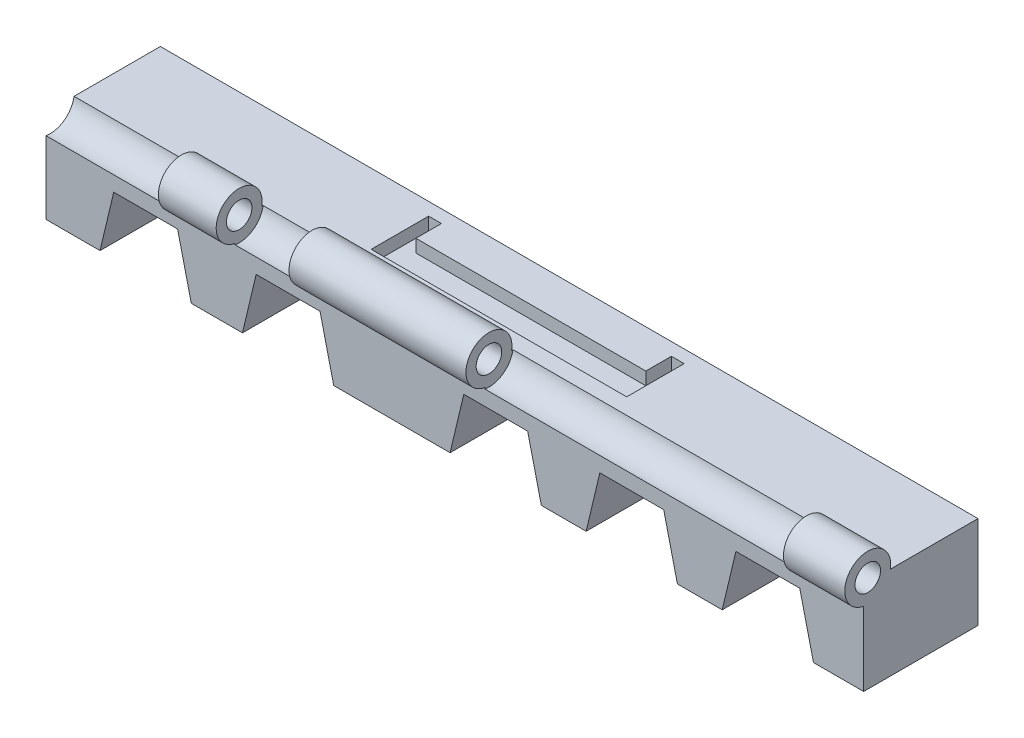
from build123d import *

# Parameters (mm, degrees)
SKETCH1_R                 = 7.62
BOSS_EXTRUDE3_DEPTH       = 127
CUT_EXTRUDE8_DEPTH        = 10.16
CUT_EXTRUDE8_DEPTH_BACK   = 20.828
SKETCH3_W                 = 3.81
SKETCH3_H                 = 18.722382306
SKETCH3_W_2               = 12.7
SKETCH5_W                 = 3.81
SKETCH5_H                 = 18.722382306
CUT_EXTRUDE9_DEPTH        = 36.576
SKETCH6_W                 = 12.7
SKETCH6_H                 = 18.722382306
SKETCH6_W_2               = 3.81
SKETCH6_W_3               = 71.12
CUT_EXTRUDE11_DEPTH       = 36.576
CUT_EXTRUDE12_DEPTH       = 20.32
CUT_EXTRUDE12_DEPTH_BACK  = 33.02
CUT_EXTRUDE21_DEPTH       = 20.32
CUT_EXTRUDE21_DEPTH_BACK  = 33.02
CUT_EXTRUDE23_DEPTH       = 20.32
CUT_EXTRUDE23_DEPTH_BACK  = 33.02
CUT_EXTRUDE26_DEPTH       = 20.32
CUT_EXTRUDE26_DEPTH_BACK  = 33.02
CUT_EXTRUDE27_DEPTH       = 20.32
CUT_EXTRUDE27_DEPTH_BACK  = 33.02
SCALE1_SCALE              = 1.3
CUT_EXTRUDE28_START       = -154.94
SKETCH26_R                = 13.065490037
CUT_EXTRUDE28_DEPTH       = 154.94
SKETCH27_W                = 13.208
SKETCH27_H                = 4.731500073
BOSS_EXTRUDE4_DEPTH       = 165.1
CUT_EXTRUDE29_DEPTH       = 14.224
CUT_EXTRUDE29_DEPTH_BACK  = 203.962
SKETCH28_W                = 13.208
SKETCH28_H                = 4.731500073
SKETCH29_W                = 150.317302473
SKETCH29_H                = 24.765
BOSS_EXTRUDE5_DEPTH       = 33.02
SKETCH30_W                = 165.1
SKETCH30_H                = 8.255
CUT_EXTRUDE30_DEPTH       = 33.02
SKETCH31_W                = 13.97
SKETCH31_H                = 16.51
CUT_EXTRUDE31_DEPTH       = 204.216
CUT_EXTRUDE32_DEPTH       = 204.216
CUT_EXTRUDE33_DEPTH       = 204.216
BOSS_EXTRUDE6_DEPTH       = 19.05
BOSS_EXTRUDE7_DEPTH       = 165.1
CUT_EXTRUDE34_DEPTH       = 165.1
CUT_EXTRUDE45_DEPTH       = 19.558
CUT_EXTRUDE45_DEPTH_BACK  = 50.8
SKETCH46_R                = 6.3627
CUT_EXTRUDE46_DEPTH       = 55.88
CUT_EXTRUDE46_DEPTH_BACK  = 50.8
SKETCH47_R                = 6.3627
CUT_EXTRUDE47_DEPTH       = 11.43
CUT_EXTRUDE47_DEPTH_BACK  = 67.818
CUT_EXTRUDE48_DEPTH       = 9.652
CUT_EXTRUDE48_DEPTH_BACK  = 67.31
SKETCH50_R                = 3.9878
SKETCH51_W                = 2.128397358
SKETCH51_H                = 21.339200712
CUT_EXTRUDE49_DEPTH       = 67.31
SKETCH52_R                = 6.604
CUT_EXTRUDE50_DEPTH       = 50.8
CUT_EXTRUDE51_START       = -50.8
SKETCH53_R                = 6.604
CUT_EXTRUDE51_DEPTH       = 50.8
BOSS_EXTRUDE8_DEPTH       = 19.05
CUT_EXTRUDE52_DEPTH       = 19.05
BOSS_EXTRUDE9_DEPTH       = 19.05
CUT_EXTRUDE53_DEPTH       = 19.05
SKETCH58_W                = 0.5461
SKETCH58_H                = 19.05
CUT_EXTRUDE54_DEPTH       = 45.974
CUT_EXTRUDE55_DEPTH       = 45.974
BOSS_EXTRUDE10_DEPTH      = 19.05
SKETCH61_W                = 0.3429
SKETCH61_H                = 19.05
CUT_EXTRUDE56_DEPTH       = 37.338
CUT_EXTRUDE60_DEPTH       = 8.89
CUT_EXTRUDE60_DEPTH_BACK  = 38.1
SKETCH75_R                = 3.175
CUT_EXTRUDE61_DEPTH       = 12.7
CUT_EXTRUDE61_DEPTH_BACK  = 67.31
SKETCH81_R                = 2.499995
BOSS_EXTRUDE11_DEPTH      = 9.398
BOSS_EXTRUDE12_START      = -9.398
BOSS_EXTRUDE12_DEPTH      = 9.398
CUT_EXTRUDE62_DEPTH       = 5.842
CUT_EXTRUDE62_DEPTH_BACK  = 24.892
BOSS_EXTRUDE13_DEPTH      = 19.05
CUT_EXTRUDE64_DEPTH       = 19.05
BOSS_EXTRUDE15_DEPTH      = 19.05
CUT_EXTRUDE65_DEPTH       = 19.05
BOSS_EXTRUDE16_DEPTH      = 19.05
CUT_EXTRUDE66_DEPTH       = 19.05
BOSS_EXTRUDE17_DEPTH      = 19.05
CUT_EXTRUDE67_DEPTH       = 19.05
BOSS_EXTRUDE18_DEPTH      = 19.05
CUT_EXTRUDE68_DEPTH       = 19.05
BOSS_EXTRUDE19_DEPTH      = 19.05
CUT_EXTRUDE69_DEPTH       = 19.05
BOSS_EXTRUDE20_DEPTH      = 19.05
CUT_EXTRUDE70_DEPTH       = 19.05
BOSS_EXTRUDE21_DEPTH      = 19.05
CUT_EXTRUDE71_DEPTH       = 10.668
CUT_EXTRUDE71_DEPTH_BACK  = 35.306
SKETCH105_R               = 2.50000008
CUT_EXTRUDE72_DEPTH       = 19.812
CUT_EXTRUDE72_DEPTH_BACK  = 56.388
SKETCH106_W               = 0.381
SKETCH106_H               = 30.850817133
SKETCH108_W               = 19.05
SKETCH108_H               = 3.81
BOSS_EXTRUDE22_DEPTH      = 162.56
SKETCH109_W               = 19.05
SKETCH109_H               = 40.733446347
CUT_EXTRUDE73_DEPTH       = 162.56
SKETCH110_R               = 3.425685186
SKETCH110_R_2             = 3.853308442
BOSS_EXTRUDE23_DEPTH      = 19.05
SKETCH111_W               = 162.56
SKETCH111_H               = 2.54
CUT_EXTRUDE76_DEPTH       = 19.05
SKETCH112_R               = 1.6002
SKETCH112_R_2             = 0.8128
BOSS_EXTRUDE25_DEPTH      = 162.56
CUT_EXTRUDE83_DEPTH       = 19.558
CUT_EXTRUDE83_DEPTH_BACK  = 29.21
SKETCH115_W               = 55.88
SKETCH115_H               = 2.413
SKETCH118_W               = 55.88
SKETCH118_H               = 0.565603497
CUT_EXTRUDE84_DEPTH       = 29.21
SKETCH119_R               = 1.778
CUT_EXTRUDE85_DEPTH       = 57.912
CUT_EXTRUDE86_START       = 65.278
SKETCH120_R               = 1.778
CUT_EXTRUDE86_DEPTH       = 65.278
BOSS_EXTRUDE26_DEPTH      = 3.6817427
SKETCH124_W               = 0.0012573
SKETCH124_H               = 16.51
BOSS_EXTRUDE27_DEPTH      = 162.56
CUT_EXTRUDE87_DEPTH       = 162.56
BOSS_EXTRUDE29_DEPTH      = 50.8
FILLET5_R                 = 0.762
SKETCH131_W               = 0.398403583
SKETCH131_H               = 0.613592462
CUT_EXTRUDE88_DEPTH       = 50.8
BOSS_EXTRUDE30_DEPTH      = 50.8
SKETCH133_W               = 0.963005867
SKETCH133_H               = 0.762
CUT_EXTRUDE89_DEPTH       = 50.8
BOSS_EXTRUDE31_DEPTH      = 50.8
BOSS_EXTRUDE33_DEPTH      = 50.8
BOSS_EXTRUDE34_DEPTH      = 50.8
BOSS_EXTRUDE36_DEPTH      = 50.8
BOSS_EXTRUDE38_DEPTH      = 50.8
CUT_EXTRUDE90_DEPTH       = 50.8
BOSS_EXTRUDE40_DEPTH      = 50.8
CUT_EXTRUDE91_DEPTH       = 50.8
BOSS_EXTRUDE41_DEPTH      = 50.8
CUT_EXTRUDE92_DEPTH       = 50.8
CUT_EXTRUDE93_DEPTH       = 50.8
CUT_EXTRUDE94_DEPTH       = 50.8
BOSS_EXTRUDE42_DEPTH      = 50.8
CUT_EXTRUDE95_DEPTH       = 50.8
BOSS_EXTRUDE43_DEPTH      = 50.8
CUT_EXTRUDE96_DEPTH       = 50.8
SKETCH150_R               = 2.54
BOSS_EXTRUDE44_DEPTH      = 50.8
SKETCH151_R               = 1.27
CUT_EXTRUDE97_DEPTH       = 50.8
SKETCH152_R               = 2.794
CUT_EXTRUDE98_DEPTH       = 68.326
CUT_EXTRUDE99_START       = 58.928
SKETCH153_R               = 2.794
CUT_EXTRUDE99_DEPTH       = 58.928
SKETCH157_W               = 5.08
SKETCH157_H               = 12.7
CUT_EXTRUDE100_DEPTH      = 5.08
SKETCH158_R               = 1.7827949
SKETCH158_R_2             = 1.016
BOSS_EXTRUDE45_DEPTH      = 50.8
SKETCH159_W               = 162.56
SKETCH159_H               = 1.905
CUT_EXTRUDE101_DEPTH      = 29.21
BOSS_EXTRUDE47_DEPTH      = 55.88
BOSS_EXTRUDE47_DEPTH_BACK = 106.68
SKETCH162_R               = 1.016
SKETCH165_R               = 2.794
CUT_EXTRUDE104_DEPTH      = 25.527
SKETCH167_R               = 2.794
CUT_EXTRUDE105_DEPTH      = 12.827
CUT_EXTRUDE106_START      = -62.357
SKETCH171_R               = 2.794
CUT_EXTRUDE106_DEPTH      = 62.357
CUT_EXTRUDE108_DEPTH      = 6.35
BOSS_EXTRUDE48_DEPTH      = 13.462
CUT_EXTRUDE109_DEPTH      = 13.462
SKETCH177_W               = 7.62
SKETCH177_H               = 13.433519273
CUT_EXTRUDE110_DEPTH      = 6.35
SKETCH178_W               = 8.89
SKETCH178_H               = 14.703519273
BOSS_EXTRUDE50_DEPTH      = 7.366
SKETCH181_W               = 0.762
SKETCH181_H               = 13.433519273
CUT_EXTRUDE113_DEPTH      = 19.558
SKETCH183_W               = 8.382
SKETCH183_H               = 13.462
CUT_EXTRUDE115_DEPTH      = 6.35
CUT_EXTRUDE117_DEPTH      = 184.404
SKETCH186_W               = 4.064
SKETCH186_H               = 2.539726593
BOSS_EXTRUDE51_DEPTH      = 162.56
SKETCH187_W               = 22.733
SKETCH187_H               = 3.81
BOSS_EXTRUDE52_DEPTH      = 162.56
SKETCH188_R               = 5.08
CUT_EXTRUDE118_DEPTH      = 162.56
SKETCH189_R               = 2.54
BOSS_EXTRUDE53_DEPTH      = 162.56
SKETCH190_W               = 7.105952381
SKETCH190_H               = 13.462
CUT_EXTRUDE119_DEPTH      = 162.56
CUT_EXTRUDE120_START      = -213.614
SKETCH191_R               = 4.572
CUT_EXTRUDE120_DEPTH      = 213.614
BOSS_EXTRUDE54_START      = -162.56
BOSS_EXTRUDE54_DEPTH      = 162.56
SKETCH193_R               = 5.08
CUT_EXTRUDE121_DEPTH      = 162.56
BOSS_EXTRUDE55_DEPTH      = 162.56
SKETCH195_R               = 2.54
BOSS_EXTRUDE56_DEPTH      = 12.192
BOSS_EXTRUDE57_START      = -11.4935
SKETCH197_R               = 2.54
BOSS_EXTRUDE57_DEPTH      = 11.4935
BOSS_EXTRUDE59_START      = -35.179
SKETCH199_R               = 2.54
BOSS_EXTRUDE59_DEPTH      = 35.179
CUT_EXTRUDE123_DEPTH      = 2.54
BOSS_EXTRUDE60_DEPTH      = 16.002


with BuildPart() as part:
    # Sketch1 → Boss-Extrude3 (new body)
    with BuildSketch(Plane(origin=(0, 0, 0), x_dir=(0, 0, -1), z_dir=(1, 0, 0))):
        with BuildLine():
            Line((0, 19.05), (0, 0))
            Line((0, 0), (25.4, 0))
            Line((25.4, 0), (25.4, 19.05))
            Line((25.4, 19.05), (17.78, 19.05))
            Line((17.78, 19.05), (17.78, 22.689615441))
            ThreePointArc((17.78, 22.689615441), (12.7, 41.411997747), (7.62, 22.689615441))
            Line((7.62, 22.689615441), (7.62, 19.05))
            Line((7.62, 19.05), (0, 19.05))
        make_face()
        with Locations((12.7, 31.361620795)):
            Circle(SKETCH1_R, mode=Mode.SUBTRACT)
    extrude(amount=BOSS_EXTRUDE3_DEPTH)

    # Sketch3 → Cut-Extrude8 (cut, two sides: drawn at the far end of the back side and taken through both)
    with BuildSketch(Plane.XY.offset(-7.62).offset(-CUT_EXTRUDE8_DEPTH_BACK)):
        with Locations((17.145, 32.050806594)):
            Rectangle(SKETCH3_W, SKETCH3_H)
        with Locations((6.35, 32.050806594)):
            Rectangle(SKETCH3_W_2, SKETCH3_H)
    extrude(amount=CUT_EXTRUDE8_DEPTH + CUT_EXTRUDE8_DEPTH_BACK, mode=Mode.SUBTRACT)

    # Sketch5 → Cut-Extrude9 (cut)
    with BuildSketch(Plane.XY):
        with Locations((23.495, 32.050806594)):
            Rectangle(SKETCH5_W, SKETCH5_H)
    extrude(amount=-CUT_EXTRUDE9_DEPTH, mode=Mode.SUBTRACT)

    # Sketch6 → Cut-Extrude11 (cut)
    with BuildSketch(Plane.XY):
        with Locations((120.65, 32.050806594)):
            Rectangle(SKETCH6_W, SKETCH6_H)
        with Locations((109.855, 32.050806594)):
            Rectangle(SKETCH6_W_2, SKETCH6_H)
        with Locations((103.505, 32.050806594)):
            Rectangle(SKETCH6_W_2, SKETCH6_H)
        with Locations((63.5, 32.050806594)):
            Rectangle(SKETCH6_W_3, SKETCH6_H)
    extrude(amount=-CUT_EXTRUDE11_DEPTH, mode=Mode.SUBTRACT)

    # Sketch7 → Cut-Extrude12 (cut, two sides: drawn at the far end of the back side and taken through both)
    with BuildSketch(Plane(origin=(0, 0, -17.78), x_dir=(-1, 0, 0), z_dir=(0, 0, -1)).offset(-CUT_EXTRUDE12_DEPTH_BACK)):
        Polygon((-116.586, 0), (-113.807281861, 15.758893664), (-108.211772717, 15.758893664), (-105.54672105, 0), align=None)
    extrude(amount=CUT_EXTRUDE12_DEPTH + CUT_EXTRUDE12_DEPTH_BACK, mode=Mode.SUBTRACT)

    # Sketch17 → Cut-Extrude21 (cut, two sides: drawn at the far end of the back side and taken through both)
    with BuildSketch(Plane.XY.offset(-CUT_EXTRUDE21_DEPTH_BACK)):
        Polygon((85.106525364, -0.117469901), (87.885243503, 15.641423763), (93.480752647, 15.641423763), (96.145804314, -0.117469901), align=None)
    extrude(amount=CUT_EXTRUDE21_DEPTH + CUT_EXTRUDE21_DEPTH_BACK, mode=Mode.SUBTRACT)

    # Sketch19 → Cut-Extrude23 (cut, two sides: drawn at the far end of the back side and taken through both)
    with BuildSketch(Plane.XY.offset(-CUT_EXTRUDE23_DEPTH_BACK)):
        Polygon((64.184734764, -0.117469901), (66.963452903, 15.641423763), (72.558962046, 15.641423763), (75.224013714, -0.117469901), align=None)
    extrude(amount=CUT_EXTRUDE23_DEPTH + CUT_EXTRUDE23_DEPTH_BACK, mode=Mode.SUBTRACT)

    # Sketch22 → Cut-Extrude26 (cut, two sides: drawn at the far end of the back side and taken through both)
    with BuildSketch(Plane.XY.offset(-CUT_EXTRUDE26_DEPTH_BACK)):
        Polygon((32.802048863, -0.117469901), (35.580767002, 15.641423763), (41.176276145, 15.641423763), (43.841327813, -0.117469901), align=None)
    extrude(amount=CUT_EXTRUDE26_DEPTH + CUT_EXTRUDE26_DEPTH_BACK, mode=Mode.SUBTRACT)

    # Sketch23 → Cut-Extrude27 (cut, two sides: drawn at the far end of the back side and taken through both)
    with BuildSketch(Plane.XY.offset(-CUT_EXTRUDE27_DEPTH_BACK)):
        Polygon((11.350592677, -0.117469901), (14.129310816, 15.641423763), (19.72481996, 15.641423763), (22.389871627, -0.117469901), align=None)
    extrude(amount=CUT_EXTRUDE27_DEPTH + CUT_EXTRUDE27_DEPTH_BACK, mode=Mode.SUBTRACT)


with BuildPart() as part_1:
    # Scale1: scaled about (62.883509837, 12.209293534, -12.7)
    add(part.part.scale(SCALE1_SCALE).moved(Location((-18.865052951, -3.66278806, 3.81))))

    # Sketch26 → Cut-Extrude28 (cut)
    with BuildSketch(Plane(origin=(129.724947049, 0, 0), x_dir=(0, 0, -1), z_dir=(1, 0, 0)).offset(CUT_EXTRUDE28_START)):
        with Locations((12.7, 37.107318973)):
            Circle(SKETCH26_R)
    extrude(amount=CUT_EXTRUDE28_DEPTH, mode=Mode.SUBTRACT)

    # Sketch27 → Boss-Extrude4 (add)
    with BuildSketch(Plane(origin=(146.234947049, 0, 0), x_dir=(0, 0, -1), z_dir=(1, 0, 0))):
        with Locations((12.7, 23.467961976)):
            Rectangle(SKETCH27_W, SKETCH27_H)
    extrude(amount=-BOSS_EXTRUDE4_DEPTH)

    # Sketch28 → Cut-Extrude29 (cut, two sides: drawn at the far end of the back side and taken through both)
    with BuildSketch(Plane.ZY.offset(18.865052951).offset(-CUT_EXTRUDE29_DEPTH_BACK)):
        with Locations((-12.7, 23.467961976)):
            Rectangle(SKETCH28_W, SKETCH28_H)
    extrude(amount=CUT_EXTRUDE29_DEPTH + CUT_EXTRUDE29_DEPTH_BACK, mode=Mode.SUBTRACT)

    # Sketch29 → Boss-Extrude5 (add)
    with BuildSketch(Plane.XY.offset(3.81)):
        with Locations((71.076295812, 8.71971194)):
            Rectangle(SKETCH29_W, SKETCH29_H)
    extrude(amount=-BOSS_EXTRUDE5_DEPTH)

    # Sketch30 → Cut-Extrude30 (cut)
    with BuildSketch(Plane(origin=(0, 0, -29.21), x_dir=(-1, 0, 0), z_dir=(0, 0, -1))):
        with Locations((-63.684947049, 16.97471194)):
            Rectangle(SKETCH30_W, SKETCH30_H)
    extrude(amount=-CUT_EXTRUDE30_DEPTH, mode=Mode.SUBTRACT)

    # Sketch31 → Cut-Extrude31 (cut)
    with BuildSketch(Plane.ZY.offset(18.865052951)):
        with Locations((-3.175, 4.59221194)):
            Rectangle(SKETCH31_W, SKETCH31_H)
    extrude(amount=-CUT_EXTRUDE31_DEPTH, mode=Mode.SUBTRACT)

    # Sketch33 → Cut-Extrude32 (cut)
    with BuildSketch(Plane(origin=(0, 0, -29.21), x_dir=(-1, 0, 0), z_dir=(0, 0, -1))):
        Polygon((-104.959947049, 9.67221194), (-108.134947049, -3.66278806), (-89.084947049, -3.66278806), (-92.259947049, 9.67221194), align=None)
        Polygon((-6.534947049, 9.67221194), (-9.709947049, -3.66278806), (9.340052951, -3.66278806), (6.165052951, 9.67221194), align=None)
        Polygon((-35.109947049, 9.67221194), (-38.284947049, -3.66278806), (-19.234947049, -3.66278806), (-22.409947049, 9.67221194), align=None)
        Polygon((-76.384947049, 9.67221194), (-79.559947049, -3.66278806), (-60.509947049, -3.66278806), (-63.684947049, 9.67221194), align=None)
    extrude(amount=-CUT_EXTRUDE32_DEPTH, mode=Mode.SUBTRACT)

    # Sketch34 → Cut-Extrude33 (cut)
    with BuildSketch(Plane.XY.offset(-10.16)):
        Polygon((136.709947049, -3.66278806), (133.534947049, 9.67221194), (120.834947049, 9.67221194), (117.659947049, -3.66278806), align=None)
    extrude(amount=-CUT_EXTRUDE33_DEPTH, mode=Mode.SUBTRACT)

    # Sketch35 → Boss-Extrude6 (add)
    with BuildSketch(Plane.XY.offset(-10.16)):
        Polygon((-18.865052951, 12.84721194), (-18.865052951, 15.38721194), (146.276628632, 15.38721194), (146.234947049, 12.84721194), align=None)
    extrude(amount=-BOSS_EXTRUDE6_DEPTH)

    # Sketch44 → Boss-Extrude7 (add)
    with BuildSketch(Plane(origin=(146.234947049, 0, 0), x_dir=(0, 0, -1), z_dir=(1, 0, 0))):
        with BuildLine():
            ThreePointArc((26.035, 19.19721194), (17.676953686, 25.221350882), (14.605, 15.38721194))
            Line((14.605, 15.38721194), (24.765, 15.38721194))
            ThreePointArc((24.765, 15.38721194), (25.709138943, 17.189165625), (26.035, 19.19721194))
        make_face()
    extrude(amount=-BOSS_EXTRUDE7_DEPTH)

    # Sketch45 → Cut-Extrude34 (cut)
    with BuildSketch(Plane(origin=(146.234947049, 0, 0), x_dir=(0, 0, -1), z_dir=(1, 0, 0))):
        with BuildLine():
            ThreePointArc((19.685, 15.38721194), (22.379076836, 16.503135103), (23.495, 19.19721194))
            ThreePointArc((23.495, 19.19721194), (16.990923164, 21.891288776), (19.685, 15.38721194))
        make_face()
    extrude(amount=-CUT_EXTRUDE34_DEPTH, mode=Mode.SUBTRACT)

    # Sketch46 → Cut-Extrude45 (cut, two sides: drawn at the far end of the back side and taken through both)
    with BuildSketch(Plane(origin=(146.234947049, 0, 0), x_dir=(0, 0, -1), z_dir=(1, 0, 0)).offset(-CUT_EXTRUDE45_DEPTH_BACK)):
        with Locations((19.685, 19.19721194)):
            Circle(SKETCH46_R)
    extrude(amount=CUT_EXTRUDE45_DEPTH + CUT_EXTRUDE45_DEPTH_BACK, mode=Mode.SUBTRACT)

    # Sketch47 → Cut-Extrude46 (cut, two sides: drawn at the far end of the back side and taken through both)
    with BuildSketch(Plane.ZY.offset(18.865052951).offset(-CUT_EXTRUDE46_DEPTH_BACK)):
        with Locations((-19.685, 19.19721194)):
            Circle(SKETCH47_R)
    extrude(amount=CUT_EXTRUDE46_DEPTH + CUT_EXTRUDE46_DEPTH_BACK, mode=Mode.SUBTRACT)

    # Sketch49 → Cut-Extrude47 (cut, two sides: drawn at the far end of the back side and taken through both)
    with BuildSketch(Plane(origin=(95.434947049, 0, 0), x_dir=(0, 0, -1), z_dir=(1, 0, 0)).offset(-CUT_EXTRUDE47_DEPTH_BACK)):
        with BuildLine():
            ThreePointArc((26.035, 19.19721194), (17.676953686, 25.221350882), (14.605, 15.38721194))
            Line((14.605, 15.38721194), (14.764671861, 15.38721194))
            ThreePointArc((14.764671861, 15.38721194), (17.671728162, 25.085544939), (25.908, 19.19721194))
            ThreePointArc((25.908, 19.19721194), (25.573332999, 17.183940102), (24.605328139, 15.38721194))
            Line((24.605328139, 15.38721194), (24.765, 15.38721194))
            ThreePointArc((24.765, 15.38721194), (25.709138943, 17.189165625), (26.035, 19.19721194))
        make_face()
    extrude(amount=CUT_EXTRUDE47_DEPTH + CUT_EXTRUDE47_DEPTH_BACK, mode=Mode.SUBTRACT)

    # Sketch50 → Cut-Extrude48 (cut, two sides: drawn at the far end of the back side and taken through both)
    with BuildSketch(Plane(origin=(95.434947049, 0, 0), x_dir=(0, 0, -1), z_dir=(1, 0, 0)).offset(-CUT_EXTRUDE48_DEPTH_BACK)):
        with Locations((19.685, 19.19721194)):
            Circle(SKETCH50_R)
    extrude(amount=CUT_EXTRUDE48_DEPTH + CUT_EXTRUDE48_DEPTH_BACK, mode=Mode.SUBTRACT)

    # Sketch51 → Cut-Extrude49 (cut)
    with BuildSketch(Plane(origin=(0, 0, -29.21), x_dir=(-1, 0, 0), z_dir=(0, 0, -1))):
        with Locations((-147.299145728, 7.006812296)):
            Rectangle(SKETCH51_W, SKETCH51_H)
    extrude(amount=-CUT_EXTRUDE49_DEPTH, mode=Mode.SUBTRACT)

    # Sketch52 → Cut-Extrude50 (cut)
    with BuildSketch(Plane(origin=(146.234947049, 0, 0), x_dir=(0, 0, -1), z_dir=(1, 0, 0))):
        with Locations((19.685, 19.19721194)):
            Circle(SKETCH52_R)
    extrude(amount=-CUT_EXTRUDE50_DEPTH, mode=Mode.SUBTRACT)

    # Sketch53 → Cut-Extrude51 (cut)
    with BuildSketch(Plane.ZY.offset(18.865052951).offset(CUT_EXTRUDE51_START)):
        with Locations((-19.685, 19.19721194)):
            Circle(SKETCH53_R)
    extrude(amount=CUT_EXTRUDE51_DEPTH, mode=Mode.SUBTRACT)

    # Sketch54 → Boss-Extrude8 (add)
    with BuildSketch(Plane.XY.offset(-10.16)):
        Polygon((-9.340052951, -3.66278806), (-7.752552951, -3.66278806), (-4.577552951, 9.67221194), (-6.165052951, 9.67221194), align=None)
    extrude(amount=-BOSS_EXTRUDE8_DEPTH)

    # Sketch55 → Cut-Extrude52 (cut)
    with BuildSketch(Plane.XY.offset(-10.16)):
        Polygon((8.122447049, 9.67221194), (6.534947049, 9.67221194), (9.709947049, -3.66278806), (11.297447049, -3.66278806), align=None)
    extrude(amount=-CUT_EXTRUDE52_DEPTH, mode=Mode.SUBTRACT)

    # Sketch56 → Boss-Extrude9 (add)
    with BuildSketch(Plane.XY.offset(-10.16)):
        Polygon((19.234947049, -3.66278806), (20.822447049, -3.66278806), (23.997447049, 9.67221194), (22.409947049, 9.67221194), align=None)
        Polygon((60.509947049, -3.66278806), (62.097447049, -3.66278806), (65.272447049, 9.67221194), (63.684947049, 9.67221194), align=None)
        Polygon((136.709947049, -3.66278806), (135.122447049, -3.66278806), (131.947447049, 9.67221194), (133.534947049, 9.67221194), align=None)
    extrude(amount=-BOSS_EXTRUDE9_DEPTH)

    # Sketch57 → Cut-Extrude53 (cut)
    with BuildSketch(Plane.XY.offset(-10.16)):
        Polygon((35.109947049, 9.67221194), (36.697447049, 9.67221194), (39.872447049, -3.66278806), (38.284947049, -3.66278806), align=None)
        Polygon((79.559947049, -3.66278806), (81.147447049, -3.66278806), (77.972447049, 9.67221194), (76.384947049, 9.67221194), align=None)
        Polygon((117.659947049, -3.66278806), (116.072447049, -3.66278806), (119.247447049, 9.67221194), (120.834947049, 9.67221194), align=None)
    extrude(amount=-CUT_EXTRUDE53_DEPTH, mode=Mode.SUBTRACT)

    # Sketch58 → Cut-Extrude54 (cut)
    with BuildSketch(Plane(origin=(0, 0, -29.21), x_dir=(-1, 0, 0), z_dir=(0, 0, -1))):
        with Locations((18.592002951, 5.86221194)):
            Rectangle(SKETCH58_W, SKETCH58_H)
        with Locations((-145.961897049, 5.86221194)):
            Rectangle(SKETCH58_W, SKETCH58_H)
    extrude(amount=-CUT_EXTRUDE54_DEPTH, mode=Mode.SUBTRACT)

    # Sketch59 → Cut-Extrude55 (cut)
    with BuildSketch(Plane.XY.offset(-10.16)):
        Polygon((-7.752552951, -3.66278806), (-8.324052951, -3.66278806), (-5.149052951, 9.67221194), (-4.577552951, 9.67221194), align=None)
        Polygon((23.997447049, 9.67221194), (23.425947049, 9.67221194), (20.250947049, -3.66278806), (20.822447049, -3.66278806), align=None)
        Polygon((62.097447049, -3.66278806), (61.525947049, -3.66278806), (64.700947049, 9.67221194), (65.272447049, 9.67221194), align=None)
        Polygon((135.122447049, -3.66278806), (135.693947049, -3.66278806), (132.518947049, 9.67221194), (131.947447049, 9.67221194), align=None)
    extrude(amount=-CUT_EXTRUDE55_DEPTH, mode=Mode.SUBTRACT)

    # Sketch60 → Boss-Extrude10 (add)
    with BuildSketch(Plane.XY.offset(-10.16)):
        Polygon((8.122447049, 9.67221194), (7.550947049, 9.67221194), (10.725947049, -3.66278806), (11.297447049, -3.66278806), align=None)
        Polygon((36.697447049, 9.67221194), (36.125947049, 9.67221194), (39.300947049, -3.66278806), (39.872447049, -3.66278806), align=None)
        Polygon((77.972447049, 9.67221194), (77.400947049, 9.67221194), (80.575947049, -3.66278806), (81.147447049, -3.66278806), align=None)
        Polygon((116.072447049, -3.66278806), (116.643947049, -3.66278806), (119.818947049, 9.67221194), (119.247447049, 9.67221194), align=None)
    extrude(amount=-BOSS_EXTRUDE10_DEPTH)

    # Sketch61 → Cut-Extrude56 (cut)
    with BuildSketch(Plane.XY.offset(-10.16)):
        with Locations((145.517397049, 5.86221194)):
            Rectangle(SKETCH61_W, SKETCH61_H)
        with Locations((-18.147502951, 5.86221194)):
            Rectangle(SKETCH61_W, SKETCH61_H)
    extrude(amount=-CUT_EXTRUDE56_DEPTH, mode=Mode.SUBTRACT)

    # Sketch75 → Cut-Extrude60 (cut, two sides: drawn at the far end of the back side and taken through both)
    with BuildSketch(Plane(origin=(0, -3.66278806, 0), x_dir=(-1, 0, 0), z_dir=(0, -1, 0)).offset(-CUT_EXTRUDE60_DEPTH_BACK)):
        with Locations((13.043301181, 19.685)):
            Circle(SKETCH75_R)
    extrude(amount=CUT_EXTRUDE60_DEPTH + CUT_EXTRUDE60_DEPTH_BACK, mode=Mode.SUBTRACT)

    # Sketch81 → Cut-Extrude61 (cut, two sides: drawn at the far end of the back side and taken through both)
    with BuildSketch(Plane(origin=(0, -3.66278806, 0), x_dir=(-1, 0, 0), z_dir=(0, -1, 0)).offset(-CUT_EXTRUDE61_DEPTH_BACK)):
        with Locations((13.043301181, 19.685)):
            Circle(SKETCH81_R)
        with Locations((-140.413195279, 19.685)):
            Circle(SKETCH81_R)
    extrude(amount=CUT_EXTRUDE61_DEPTH + CUT_EXTRUDE61_DEPTH_BACK, mode=Mode.SUBTRACT)

    # Sketch85 → Boss-Extrude11 (add)
    with BuildSketch(Plane(origin=(145.345947049, 0, 0), x_dir=(0, 0, -1), z_dir=(1, 0, 0))):
        with BuildLine():
            Line((14.290862812, 15.38721194), (10.16, 15.38721194))
            Line((10.16, 15.38721194), (10.16, -3.66278806))
            Line((10.16, -3.66278806), (29.21, -3.66278806))
            Line((29.21, -3.66278806), (29.21, 15.38721194))
            Line((29.21, 15.38721194), (25.079137188, 15.38721194))
            ThreePointArc((25.079137188, 15.38721194), (19.685, 12.59321194), (14.290862812, 15.38721194))
        make_face()
    extrude(amount=-BOSS_EXTRUDE11_DEPTH)

    # Sketch86 → Boss-Extrude12 (add)
    with BuildSketch(Plane.ZY.offset(17.976052951).offset(BOSS_EXTRUDE12_START)):
        with BuildLine():
            Line((-25.079137188, 15.38721194), (-29.21, 15.38721194))
            Line((-29.21, 15.38721194), (-29.21, -3.66278806))
            Line((-29.21, -3.66278806), (-10.16, -3.66278806))
            Line((-10.16, -3.66278806), (-10.16, 15.38721194))
            Line((-10.16, 15.38721194), (-14.290862812, 15.38721194))
            ThreePointArc((-14.290862812, 15.38721194), (-19.685, 12.59321194), (-25.079137188, 15.38721194))
        make_face()
    extrude(amount=BOSS_EXTRUDE12_DEPTH)

    # Sketch87 → Cut-Extrude62 (cut, two sides: drawn at the far end of the back side and taken through both)
    with BuildSketch(Plane.XY.offset(-10.16).offset(-CUT_EXTRUDE62_DEPTH_BACK)):
        Polygon((116.643947049, -3.66278806), (119.818947049, 9.67221194), (119.564947049, 9.67221194), (116.389947049, -3.66278806), align=None)
    extrude(amount=CUT_EXTRUDE62_DEPTH + CUT_EXTRUDE62_DEPTH_BACK, mode=Mode.SUBTRACT)

    # Sketch88 → Boss-Extrude13 (add)
    with BuildSketch(Plane.XY.offset(-10.16)):
        Polygon((135.693947049, -3.66278806), (132.518947049, 9.67221194), (132.264947049, 9.67221194), (135.439947049, -3.66278806), align=None)
    extrude(amount=-BOSS_EXTRUDE13_DEPTH)

    # Sketch89 → Cut-Extrude64 (cut)
    with BuildSketch(Plane.XY.offset(-10.16)):
        Polygon((77.400947049, 9.67221194), (80.575947049, -3.66278806), (80.829947049, -3.66278806), (77.654947049, 9.67221194), align=None)
    extrude(amount=-CUT_EXTRUDE64_DEPTH, mode=Mode.SUBTRACT)

    # Sketch91 → Boss-Extrude15 (add)
    with BuildSketch(Plane.XY.offset(-10.16)):
        Polygon((61.525947049, -3.66278806), (64.700947049, 9.67221194), (64.954947049, 9.67221194), (61.779947049, -3.66278806), align=None)
    extrude(amount=-BOSS_EXTRUDE15_DEPTH)

    # Sketch92 → Cut-Extrude65 (cut)
    with BuildSketch(Plane.XY.offset(-10.16)):
        Polygon((80.829947049, -3.66278806), (81.083947049, -3.66278806), (77.908947049, 9.67221194), (77.654947049, 9.67221194), align=None)
    extrude(amount=-CUT_EXTRUDE65_DEPTH, mode=Mode.SUBTRACT)

    # Sketch93 → Boss-Extrude16 (add)
    with BuildSketch(Plane.XY.offset(-10.16)):
        Polygon((64.954947049, 9.67221194), (61.779947049, -3.66278806), (62.033947049, -3.66278806), (65.208947049, 9.67221194), align=None)
    extrude(amount=-BOSS_EXTRUDE16_DEPTH)

    # Sketch94 → Cut-Extrude66 (cut)
    with BuildSketch(Plane.XY.offset(-10.16)):
        Polygon((108.134947049, -3.66278806), (104.959947049, 9.67221194), (105.213947049, 9.67221194), (108.388947049, -3.66278806), align=None)
    extrude(amount=-CUT_EXTRUDE66_DEPTH, mode=Mode.SUBTRACT)

    # Sketch95 → Boss-Extrude17 (add)
    with BuildSketch(Plane.XY.offset(-10.16)):
        Polygon((92.259947049, 9.67221194), (92.513947049, 9.67221194), (89.338947049, -3.66278806), (89.084947049, -3.66278806), align=None)
    extrude(amount=-BOSS_EXTRUDE17_DEPTH)

    # Sketch96 → Cut-Extrude67 (cut)
    with BuildSketch(Plane.XY.offset(-10.16)):
        Polygon((81.083947049, -3.66278806), (81.337947049, -3.66278806), (78.162947049, 9.67221194), (77.908947049, 9.67221194), align=None)
    extrude(amount=-CUT_EXTRUDE67_DEPTH, mode=Mode.SUBTRACT)

    # Sketch97 → Boss-Extrude18 (add)
    with BuildSketch(Plane.XY.offset(-10.16)):
        Polygon((62.033947049, -3.66278806), (65.208947049, 9.67221194), (65.462947049, 9.67221194), (62.287947049, -3.66278806), align=None)
    extrude(amount=-BOSS_EXTRUDE18_DEPTH)

    # Sketch98 → Cut-Extrude68 (cut)
    with BuildSketch(Plane.XY.offset(-10.16)):
        Polygon((39.300947049, -3.66278806), (39.808947049, -3.66278806), (36.633947049, 9.67221194), (36.125947049, 9.67221194), align=None)
    extrude(amount=-CUT_EXTRUDE68_DEPTH, mode=Mode.SUBTRACT)

    # Sketch99 → Boss-Extrude19 (add)
    with BuildSketch(Plane.XY.offset(-10.16)):
        Polygon((20.250947049, -3.66278806), (20.758947049, -3.66278806), (23.933947049, 9.67221194), (23.425947049, 9.67221194), align=None)
    extrude(amount=-BOSS_EXTRUDE19_DEPTH)

    # Sketch100 → Cut-Extrude69 (cut)
    with BuildSketch(Plane.XY.offset(-10.16)):
        Polygon((39.808947049, -3.66278806), (36.633947049, 9.67221194), (36.887947049, 9.67221194), (40.062947049, -3.66278806), align=None)
    extrude(amount=-CUT_EXTRUDE69_DEPTH, mode=Mode.SUBTRACT)

    # Sketch101 → Boss-Extrude20 (add)
    with BuildSketch(Plane.XY.offset(-10.16)):
        Polygon((20.758947049, -3.66278806), (21.012947049, -3.66278806), (24.187947049, 9.67221194), (23.933947049, 9.67221194), align=None)
    extrude(amount=-BOSS_EXTRUDE20_DEPTH)

    # Sketch102 → Cut-Extrude70 (cut)
    with BuildSketch(Plane.XY.offset(-10.16)):
        Polygon((10.725947049, -3.66278806), (11.741947049, -3.66278806), (8.566947049, 9.67221194), (7.550947049, 9.67221194), align=None)
    extrude(amount=-CUT_EXTRUDE70_DEPTH, mode=Mode.SUBTRACT)

    # Sketch103 → Boss-Extrude21 (add)
    with BuildSketch(Plane.XY.offset(-10.16)):
        Polygon((-8.324052951, -3.66278806), (-5.149052951, 9.67221194), (-4.133052951, 9.67221194), (-7.308052951, -3.66278806), align=None)
    extrude(amount=-BOSS_EXTRUDE21_DEPTH)

    # Sketch105 → Cut-Extrude71 (cut, two sides: drawn at the far end of the back side and taken through both)
    with BuildSketch(Plane(origin=(0, -3.66278806, 0), x_dir=(-1, 0, 0), z_dir=(0, -1, 0)).offset(-CUT_EXTRUDE71_DEPTH_BACK)):
        with Locations((-140.392947049, 19.685)):
            Circle(SKETCH105_R)
        with Locations((13.023052951, 19.685)):
            Circle(SKETCH105_R)
    extrude(amount=CUT_EXTRUDE71_DEPTH + CUT_EXTRUDE71_DEPTH_BACK, mode=Mode.SUBTRACT)

    # Sketch106 → Cut-Extrude72 (cut, two sides: drawn at the far end of the back side and taken through both)
    with BuildSketch(Plane.XY.offset(-10.16).offset(-CUT_EXTRUDE72_DEPTH_BACK)):
        with Locations((145.155447049, 11.762620507)):
            Rectangle(SKETCH106_W, SKETCH106_H)
        with Locations((-17.785552951, 11.762620507)):
            Rectangle(SKETCH106_W, SKETCH106_H)
    extrude(amount=CUT_EXTRUDE72_DEPTH + CUT_EXTRUDE72_DEPTH_BACK, mode=Mode.SUBTRACT)

    # Sketch108 → Boss-Extrude22 (add)
    with BuildSketch(Plane.ZY.offset(17.595052951)):
        with Locations((-19.685, 13.48221194)):
            Rectangle(SKETCH108_W, SKETCH108_H)
    extrude(amount=-BOSS_EXTRUDE22_DEPTH)

    # Sketch109 → Cut-Extrude73 (cut)
    with BuildSketch(Plane(origin=(144.964947049, 0, 0), x_dir=(0, 0, -1), z_dir=(1, 0, 0))):
        with Locations((19.685, 35.753935114)):
            Rectangle(SKETCH109_W, SKETCH109_H)
    extrude(amount=-CUT_EXTRUDE73_DEPTH, mode=Mode.SUBTRACT)

    # Sketch110 → Boss-Extrude23 (add)
    with BuildSketch(Plane(origin=(0, -3.66278806, 0), x_dir=(-1, 0, 0), z_dir=(0, -1, 0))):
        with Locations((13.023052951, 19.685)):
            Circle(SKETCH110_R)
        with Locations((-140.392947049, 19.685)):
            Circle(SKETCH110_R_2)
    extrude(amount=-BOSS_EXTRUDE23_DEPTH)

    # Sketch111 → Cut-Extrude76 (cut)
    with BuildSketch(Plane.XY.offset(-10.16)):
        with Locations((63.684947049, 14.11721194)):
            Rectangle(SKETCH111_W, SKETCH111_H)
    extrude(amount=-CUT_EXTRUDE76_DEPTH, mode=Mode.SUBTRACT)

    # Sketch112 → Boss-Extrude25 (add)
    with BuildSketch(Plane(origin=(144.964947049, 0, 0), x_dir=(0, 0, -1), z_dir=(1, 0, 0))):
        with Locations((10.9728, 13.66001194)):
            Circle(SKETCH112_R)
        with Locations((10.9728, 13.66001194)):
            Circle(SKETCH112_R_2, mode=Mode.SUBTRACT)
    extrude(amount=-BOSS_EXTRUDE25_DEPTH)

    # Sketch115 → Cut-Extrude83 (cut, two sides: drawn at the far end of the back side and taken through both)
    with BuildSketch(Plane.XY.offset(-10.16).offset(-CUT_EXTRUDE83_DEPTH_BACK)):
        with Locations((10.344947049, 14.05371194)):
            Rectangle(SKETCH115_W, SKETCH115_H)
        with Locations((117.024947049, 14.05371194)):
            Rectangle(SKETCH115_W, SKETCH115_H)
    extrude(amount=CUT_EXTRUDE83_DEPTH + CUT_EXTRUDE83_DEPTH_BACK, mode=Mode.SUBTRACT)

    # Sketch118 → Cut-Extrude84 (cut)
    with BuildSketch(Plane(origin=(0, -3.66278806, 0), x_dir=(-1, 0, 0), z_dir=(0, -1, 0))):
        with Locations((-10.344947049, 9.877198252)):
            Rectangle(SKETCH118_W, SKETCH118_H)
        with Locations((-117.024947049, 9.877198252)):
            Rectangle(SKETCH118_W, SKETCH118_H)
    extrude(amount=-CUT_EXTRUDE84_DEPTH, mode=Mode.SUBTRACT)

    # Sketch119 → Cut-Extrude85 (cut)
    with BuildSketch(Plane.ZY.offset(-38.284947049)):
        with Locations((-10.9728, 13.66001194)):
            Circle(SKETCH119_R)
    extrude(amount=CUT_EXTRUDE85_DEPTH, mode=Mode.SUBTRACT)

    # Sketch120 → Cut-Extrude86 (cut)
    with BuildSketch(Plane(origin=(89.084947049, 0, 0), x_dir=(0, 0, -1), z_dir=(1, 0, 0)).offset(CUT_EXTRUDE86_START)):
        with Locations((10.9728, 13.66001194)):
            Circle(SKETCH120_R)
    extrude(amount=-CUT_EXTRUDE86_DEPTH, mode=Mode.SUBTRACT)

    # Sketch122 → Boss-Extrude26 (add)
    with BuildSketch(Plane(origin=(0, 0, -29.21), x_dir=(-1, 0, 0), z_dir=(0, 0, -1))):
        Polygon((-144.964947049, -3.66278806), (-135.439947049, -3.66278806), (-132.264947049, 9.67221194), (-119.564947049, 9.67221194), (-116.389947049, -3.66278806), (-108.388947049, -3.66278806), (-105.213947049, 9.67221194), (-92.513947049, 9.67221194), (-89.338947049, -3.66278806), (-81.337947049, -3.66278806), (-78.162947049, 9.67221194), (-65.462947049, 9.67221194), (-62.287947049, -3.66278806), (-40.062947049, -3.66278806), (-36.887947049, 9.67221194), (-24.187947049, 9.67221194), (-21.012947049, -3.66278806), (-11.741947049, -3.66278806), (-8.566947049, 9.67221194), (4.133052951, 9.67221194), (7.308052951, -3.66278806), (17.595052951, -3.66278806), (17.595052951, 12.84721194), (-144.964947049, 12.84721194), align=None)
    extrude(amount=BOSS_EXTRUDE26_DEPTH)

    # Sketch124 → Boss-Extrude27 (add)
    with BuildSketch(Plane(origin=(144.964947049, 0, 0), x_dir=(0, 0, -1), z_dir=(1, 0, 0))):
        with Locations((32.89237135, 4.59221194)):
            Rectangle(SKETCH124_W, SKETCH124_H)
    extrude(amount=-BOSS_EXTRUDE27_DEPTH)

    # Sketch125 → Cut-Extrude87 (cut)
    with BuildSketch(Plane.XY.offset(-10.16)):
        Polygon((135.439947049, -3.66278806), (132.264947049, 9.67221194), (119.564947049, 9.67221194), (116.389947049, -3.66278806), align=None)
        Polygon((108.388947049, -3.66278806), (105.213947049, 9.67221194), (92.513947049, 9.67221194), (89.338947049, -3.66278806), align=None)
        Polygon((81.337947049, -3.66278806), (78.162947049, 9.67221194), (65.462947049, 9.67221194), (62.287947049, -3.66278806), align=None)
        Polygon((24.187947049, 9.67221194), (36.887947049, 9.67221194), (40.062947049, -3.66278806), (21.012947049, -3.66278806), align=None)
        Polygon((11.741947049, -3.66278806), (8.566947049, 9.67221194), (-4.133052951, 9.67221194), (-7.308052951, -3.66278806), align=None)
    extrude(amount=-CUT_EXTRUDE87_DEPTH, mode=Mode.SUBTRACT)

    # Sketch129 → Boss-Extrude29 (add)
    with BuildSketch(Plane.ZY.offset(-38.284947049)):
        Polygon((-24.511, 14.11721194), (-25.244234842, 12.84721194), (-24.511, 12.84721194), align=None)
    extrude(amount=-BOSS_EXTRUDE29_DEPTH)

    # Fillet5
    fillet5_edges = [part_1.edges().sort_by_distance(p)[0] for p in [
        (63.684947049, 12.84721194, -24.511),
    ]]
    fillet(fillet5_edges, radius=FILLET5_R)

    # Sketch131 → Cut-Extrude88 (cut)
    with BuildSketch(Plane.ZY.offset(-38.284947049)):
        with Locations((-24.710201792, 13.916008171)):
            Rectangle(SKETCH131_W, SKETCH131_H)
    extrude(amount=-CUT_EXTRUDE88_DEPTH, mode=Mode.SUBTRACT)

    # Sketch132 → Boss-Extrude30 (add)
    with BuildSketch(Plane.ZY.offset(-38.284947049)):
        Polygon((-24.804293937, 13.60921194), (-24.511, 13.60921194), (-24.511, 14.11721194), (-24.765, 14.11721194), (-25.498234842, 12.84721194), (-25.244234842, 12.84721194), align=None)
    extrude(amount=-BOSS_EXTRUDE30_DEPTH)

    # Sketch133 → Cut-Extrude89 (cut)
    with BuildSketch(Plane.ZY.offset(-38.284947049)):
        with Locations((-24.029497067, 13.22821194)):
            Rectangle(SKETCH133_W, SKETCH133_H)
    extrude(amount=-CUT_EXTRUDE89_DEPTH, mode=Mode.SUBTRACT)

    # Sketch134 → Boss-Extrude31 (add)
    with BuildSketch(Plane.ZY.offset(-38.284947049)):
        Polygon((-23.777765158, 12.84721194), (-24.511, 14.11721194), (-24.511, 12.84721194), align=None)
    extrude(amount=-BOSS_EXTRUDE31_DEPTH)

    # Sketch135 → Boss-Extrude33 (add)
    with BuildSketch(Plane.ZY.offset(-38.284947049)):
        Polygon((-21.774530316, 14.11721194), (-22.507765158, 12.84721194), (-20.787295474, 12.84721194), (-21.520530316, 14.11721194), align=None)
    extrude(amount=-BOSS_EXTRUDE33_DEPTH)

    # Sketch136 → Boss-Extrude34 (add)
    with BuildSketch(Plane.ZY.offset(-38.284947049)):
        Polygon((-18.784060633, 14.11721194), (-19.517295474, 12.84721194), (-17.796825791, 12.84721194), (-18.530060633, 14.11721194), align=None)
    extrude(amount=-BOSS_EXTRUDE34_DEPTH)

    # Sketch137 → Boss-Extrude36 (add)
    with BuildSketch(Plane.ZY.offset(-38.284947049)):
        Polygon((-15.031590949, 14.11721194), (-15.764825791, 12.84721194), (-14.044356107, 12.84721194), (-14.777590949, 14.11721194), align=None)
    extrude(amount=-BOSS_EXTRUDE36_DEPTH)

    # Sketch138 → Boss-Extrude38 (add)
    with BuildSketch(Plane.ZY.offset(-38.284947049)):
        Polygon((-22.155530316, 14.11721194), (-21.901530316, 14.11721194), (-21.168295474, 12.84721194), (-22.507765158, 12.84721194), (-22.888765158, 12.84721194), align=None)
    extrude(amount=-BOSS_EXTRUDE38_DEPTH)

    # Sketch139 → Cut-Extrude90 (cut)
    with BuildSketch(Plane.ZY.offset(-38.284947049)):
        Polygon((-21.774530316, 14.11721194), (-21.838030316, 14.007226713), (-21.168295474, 12.84721194), (-20.787295474, 12.84721194), (-21.520530316, 14.11721194), align=None)
    extrude(amount=-CUT_EXTRUDE90_DEPTH, mode=Mode.SUBTRACT)

    # Sketch140 → Boss-Extrude40 (add)
    with BuildSketch(Plane.ZY.offset(-38.284947049)):
        Polygon((-19.419060633, 14.11721194), (-20.152295474, 12.84721194), (-18.431825791, 12.84721194), (-19.165060633, 14.11721194), align=None)
    extrude(amount=-BOSS_EXTRUDE40_DEPTH)

    # Sketch141 → Cut-Extrude91 (cut)
    with BuildSketch(Plane.ZY.offset(-38.284947049)):
        Polygon((-18.784060633, 14.11721194), (-18.974560633, 13.787256261), (-18.431825791, 12.84721194), (-17.796825791, 12.84721194), (-18.530060633, 14.11721194), align=None)
    extrude(amount=-CUT_EXTRUDE91_DEPTH, mode=Mode.SUBTRACT)

    # Sketch142 → Boss-Extrude41 (add)
    with BuildSketch(Plane.ZY.offset(-38.284947049)):
        Polygon((-16.555590949, 14.11721194), (-17.288825791, 12.84721194), (-15.568356107, 12.84721194), (-16.301590949, 14.11721194), align=None)
    extrude(amount=-BOSS_EXTRUDE41_DEPTH)

    # Sketch143 → Cut-Extrude92 (cut)
    with BuildSketch(Plane.ZY.offset(-38.284947049)):
        Polygon((-15.905214784, 13.430668284), (-15.568356107, 12.84721194), (-13.93741625, 12.84721194), (-13.93741625, 14.317403166), (-15.905214784, 14.317403166), align=None)
    extrude(amount=-CUT_EXTRUDE92_DEPTH, mode=Mode.SUBTRACT)

    # Sketch144 → Cut-Extrude93 (cut)
    with BuildSketch(Plane.ZY.offset(-38.284947049)):
        Polygon((-24.511, 14.11721194), (-25.244234842, 12.84721194), (-25.589848365, 12.84721194), (-25.393268186, 14.11721194), align=None)
    extrude(amount=-CUT_EXTRUDE93_DEPTH, mode=Mode.SUBTRACT)

    # Sketch145 → Cut-Extrude94 (cut)
    with BuildSketch(Plane.ZY.offset(-38.284947049)):
        Polygon((-22.155530316, 14.11721194), (-21.422295474, 12.84721194), (-20.67498598, 12.84721194), (-21.275718143, 14.625171735), align=None)
        Polygon((-19.419060633, 14.11721194), (-18.685825791, 12.84721194), (-18.16633583, 12.84721194), (-18.16633583, 14.625171735), (-18.918930875, 14.625171735), align=None)
        Polygon((-16.555590949, 14.11721194), (-15.822356107, 12.84721194), (-15.221972759, 12.84721194), (-15.221972759, 14.70879183), (-16.0933986, 14.70879183), align=None)
    extrude(amount=-CUT_EXTRUDE94_DEPTH, mode=Mode.SUBTRACT)

    # Sketch146 → Boss-Extrude42 (add)
    with BuildSketch(Plane.ZY.offset(-38.284947049)):
        Polygon((-19.673060633, 14.11721194), (-20.406295474, 12.84721194), (-18.939825791, 12.84721194), align=None)
    extrude(amount=-BOSS_EXTRUDE42_DEPTH)

    # Sketch147 → Cut-Extrude95 (cut)
    with BuildSketch(Plane.ZY.offset(-38.284947049)):
        Polygon((-19.673060633, 14.11721194), (-18.939825791, 12.84721194), (-18.125191667, 12.84721194), (-19.271821176, 14.628211837), align=None)
    extrude(amount=-CUT_EXTRUDE95_DEPTH, mode=Mode.SUBTRACT)

    # Sketch148 → Boss-Extrude43 (add)
    with BuildSketch(Plane.ZY.offset(-38.284947049)):
        Polygon((-17.063590949, 14.11721194), (-17.796825791, 12.84721194), (-16.330356107, 12.84721194), align=None)
    extrude(amount=-BOSS_EXTRUDE43_DEPTH)

    # Sketch149 → Cut-Extrude96 (cut)
    with BuildSketch(Plane.ZY.offset(-38.284947049)):
        Polygon((-17.063590949, 14.11721194), (-16.330356107, 12.84721194), (-15.096027506, 12.84721194), (-16.179656352, 15.093469906), align=None)
    extrude(amount=-CUT_EXTRUDE96_DEPTH, mode=Mode.SUBTRACT)

    # Sketch150 → Boss-Extrude44 (add)
    with BuildSketch(Plane.ZY.offset(-38.284947049)):
        with Locations((-10.9728, 13.66001194)):
            Circle(SKETCH150_R)
    extrude(amount=-BOSS_EXTRUDE44_DEPTH)

    # Sketch151 → Cut-Extrude97 (cut)
    with BuildSketch(Plane.ZY.offset(-38.284947049)):
        with Locations((-10.9728, 13.66001194)):
            Circle(SKETCH151_R)
    extrude(amount=-CUT_EXTRUDE97_DEPTH, mode=Mode.SUBTRACT)

    # Sketch152 → Cut-Extrude98 (cut)
    with BuildSketch(Plane.ZY.offset(-38.284947049)):
        with Locations((-10.9728, 13.66001194)):
            Circle(SKETCH152_R)
    extrude(amount=CUT_EXTRUDE98_DEPTH, mode=Mode.SUBTRACT)

    # Sketch153 → Cut-Extrude99 (cut)
    with BuildSketch(Plane(origin=(89.084947049, 0, 0), x_dir=(0, 0, -1), z_dir=(1, 0, 0)).offset(CUT_EXTRUDE99_START)):
        with Locations((10.9728, 13.66001194)):
            Circle(SKETCH153_R)
    extrude(amount=-CUT_EXTRUDE99_DEPTH, mode=Mode.SUBTRACT)

    # Sketch157 → Cut-Extrude100 (cut)
    with BuildSketch(Plane(origin=(0, 12.84721194, 0), x_dir=(1, 0, 0), z_dir=(0, 1, 0))):
        with Locations((112.452947049, 24.539480727)):
            Rectangle(SKETCH157_W, SKETCH157_H)
    extrude(amount=-CUT_EXTRUDE100_DEPTH, mode=Mode.SUBTRACT)

    # Sketch158 → Boss-Extrude45 (add)
    with BuildSketch(Plane(origin=(89.084947049, 0, 0), x_dir=(0, 0, -1), z_dir=(1, 0, 0))):
        with Locations((10.9728, 13.66001194)):
            Circle(SKETCH158_R)
        with Locations((10.9728, 13.66001194)):
            Circle(SKETCH158_R_2, mode=Mode.SUBTRACT)
    extrude(amount=-BOSS_EXTRUDE45_DEPTH)

    # Sketch159 → Cut-Extrude101 (cut)
    with BuildSketch(Plane.XY.offset(-10.16)):
        with Locations((63.684947049, -2.71028806)):
            Rectangle(SKETCH159_W, SKETCH159_H)
    extrude(amount=-CUT_EXTRUDE101_DEPTH, mode=Mode.SUBTRACT)

    # Sketch162 → Boss-Extrude47 (add, two sides: drawn at the far end of the back side and taken through both)
    with BuildSketch(Plane(origin=(89.084947049, 0, 0), x_dir=(0, 0, -1), z_dir=(1, 0, 0)).offset(-BOSS_EXTRUDE47_DEPTH_BACK)):
        with BuildLine():
            Line((10.16, 11.253571382), (10.16, 10.986850486))
            ThreePointArc((10.16, 10.986850486), (12.2882742, 11.195064957), (13.645961454, 12.84721194))
            Line((13.645961454, 12.84721194), (13.379240558, 12.84721194))
            ThreePointArc((13.379240558, 12.84721194), (9.845925955, 15.936358769), (10.16, 11.253571382))
        make_face()
        with Locations((10.9728, 13.66001194)):
            Circle(SKETCH162_R, mode=Mode.SUBTRACT)
    extrude(amount=BOSS_EXTRUDE47_DEPTH + BOSS_EXTRUDE47_DEPTH_BACK)

    # Sketch165 → Cut-Extrude104 (cut)
    with BuildSketch(Plane.ZY.offset(17.595052951)):
        with Locations((-10.9728, 13.66001194)):
            Circle(SKETCH165_R)
    extrude(amount=-CUT_EXTRUDE104_DEPTH, mode=Mode.SUBTRACT)

    # Sketch167 → Cut-Extrude105 (cut)
    with BuildSketch(Plane.ZY.offset(-20.504947049)):
        with Locations((-10.9728, 13.66001194)):
            Circle(SKETCH167_R)
    extrude(amount=-CUT_EXTRUDE105_DEPTH, mode=Mode.SUBTRACT)

    # Sketch171 → Cut-Extrude106 (cut)
    with BuildSketch(Plane(origin=(132.264947049, 0, 0), x_dir=(0, 0, -1), z_dir=(1, 0, 0)).offset(CUT_EXTRUDE106_START)):
        with Locations((10.9728, 13.66001194)):
            Circle(SKETCH171_R)
    extrude(amount=CUT_EXTRUDE106_DEPTH, mode=Mode.SUBTRACT)

    # Sketch173 → Cut-Extrude108 (cut)
    with BuildSketch(Plane(origin=(0, 12.84721194, 0), x_dir=(1, 0, 0), z_dir=(0, 1, 0))):
        Polygon((108.642947049, 18.189480727), (117.532947049, 18.189480727), (117.532947049, 30.889480727), (117.532947049, 32.893), (108.642947049, 32.893), (108.642947049, 30.889480727), align=None)
    extrude(amount=-CUT_EXTRUDE108_DEPTH, mode=Mode.SUBTRACT)

    # Sketch174 → Boss-Extrude48 (add)
    with BuildSketch(Plane(origin=(144.964947049, 0, 0), x_dir=(0, 0, -1), z_dir=(1, 0, 0))):
        with BuildLine():
            Line((32.893, -1.75778806), (32.893, 12.84721194))
            Line((32.893, 12.84721194), (13.645961454, 12.84721194))
            ThreePointArc((13.645961454, 12.84721194), (12.2882742, 11.195064957), (10.16, 10.986850486))
            Line((10.16, 10.986850486), (10.16, -1.75778806))
            Line((10.16, -1.75778806), (32.893, -1.75778806))
        make_face()
    extrude(amount=BOSS_EXTRUDE48_DEPTH)

    # Sketch175 → Cut-Extrude109 (cut)
    with BuildSketch(Plane(origin=(158.426947049, 0, 0), x_dir=(0, 0, -1), z_dir=(1, 0, 0))):
        Polygon((4.210920431, -11.523772982), (50.210590398, -9.653496796), (48.574452832, 30.587505382), (-24.727839078, 24.385529785), align=None)
    extrude(amount=-CUT_EXTRUDE109_DEPTH, mode=Mode.SUBTRACT)

    # Sketch177 → Cut-Extrude110 (cut)
    with BuildSketch(Plane(origin=(0, 12.84721194, 0), x_dir=(1, 0, 0), z_dir=(0, 1, 0))):
        with Locations((121.342947049, 24.906240364)):
            Rectangle(SKETCH177_W, SKETCH177_H)
    extrude(amount=-CUT_EXTRUDE110_DEPTH, mode=Mode.SUBTRACT)

    # Sketch178 → Boss-Extrude50 (add)
    with BuildSketch(Plane(origin=(0, 12.84721194, 0), x_dir=(1, 0, 0), z_dir=(0, 1, 0))):
        with Locations((113.087947049, 25.541240364)):
            Rectangle(SKETCH178_W, SKETCH178_H)
    extrude(amount=-BOSS_EXTRUDE50_DEPTH)

    # Sketch181 → Cut-Extrude113 (cut)
    with BuildSketch(Plane(origin=(0, 12.84721194, 0), x_dir=(1, 0, 0), z_dir=(0, 1, 0))):
        with Locations((125.533947049, 24.906240364)):
            Rectangle(SKETCH181_W, SKETCH181_H)
    extrude(amount=-CUT_EXTRUDE113_DEPTH, mode=Mode.SUBTRACT)

    # Sketch183 → Cut-Extrude115 (cut)
    with BuildSketch(Plane(origin=(0, 12.84721194, 0), x_dir=(1, 0, 0), z_dir=(0, 1, 0))):
        with Locations((121.723947049, 24.892)):
            Rectangle(SKETCH183_W, SKETCH183_H)
    extrude(amount=-CUT_EXTRUDE115_DEPTH, mode=Mode.SUBTRACT)

    # Sketch185 → Cut-Extrude117 (cut)
    with BuildSketch(Plane(origin=(144.964947049, 0, 0), x_dir=(0, 0, -1), z_dir=(1, 0, 0))):
        Polygon((6.531043178, 11.253571382), (10.16, 11.253571382), (10.16, 12.84721194), (13.753726865, 12.84721194), (13.753726865, 17.268899465), (6.531043178, 17.268899465), align=None)
    extrude(amount=-CUT_EXTRUDE117_DEPTH, mode=Mode.SUBTRACT)

    # Sketch186 → Boss-Extrude51 (add)
    with BuildSketch(Plane(origin=(144.964947049, 0, 0), x_dir=(0, 0, -1), z_dir=(1, 0, 0))):
        with Locations((12.192, 11.577348644)):
            Rectangle(SKETCH186_W, SKETCH186_H)
    extrude(amount=-BOSS_EXTRUDE51_DEPTH)

    # Sketch187 → Boss-Extrude52 (add)
    with BuildSketch(Plane(origin=(144.964947049, 0, 0), x_dir=(0, 0, -1), z_dir=(1, 0, 0))):
        with Locations((21.5265, 14.75221194)):
            Rectangle(SKETCH187_W, SKETCH187_H)
    extrude(amount=-BOSS_EXTRUDE52_DEPTH)

    # Sketch188 → Cut-Extrude118 (cut)
    with BuildSketch(Plane(origin=(144.964947049, 0, 0), x_dir=(0, 0, -1), z_dir=(1, 0, 0))):
        with Locations((10.16, 16.65721194)):
            Circle(SKETCH188_R)
    extrude(amount=-CUT_EXTRUDE118_DEPTH, mode=Mode.SUBTRACT)

    # Sketch189 → Boss-Extrude53 (add)
    with BuildSketch(Plane(origin=(144.964947049, 0, 0), x_dir=(0, 0, -1), z_dir=(1, 0, 0))):
        with BuildLine():
            ThreePointArc((10.16, 11.57721194), (13.752102448, 13.065109491), (15.24, 16.65721194))
            Line((15.24, 16.65721194), (14.732, 16.65721194))
            ThreePointArc((14.732, 16.65721194), (6.927107796, 19.890104143), (10.16, 12.08521194))
            Line((10.16, 12.08521194), (10.16, 11.57721194))
        make_face()
        with Locations((10.16, 16.65721194)):
            Circle(SKETCH189_R, mode=Mode.SUBTRACT)
    extrude(amount=-BOSS_EXTRUDE53_DEPTH)

    # Sketch190 → Cut-Extrude119 (cut)
    with BuildSketch(Plane.XZ.offset(-9.67221194)):
        with Locations((122.361970859, -24.892)):
            Rectangle(SKETCH190_W, SKETCH190_H)
    extrude(amount=-CUT_EXTRUDE119_DEPTH, mode=Mode.SUBTRACT)

    # Sketch191 → Cut-Extrude120 (cut)
    with BuildSketch(Plane.ZY.offset(17.595052951).offset(CUT_EXTRUDE120_START)):
        with Locations((-10.16, 16.65721194)):
            Circle(SKETCH191_R)
    extrude(amount=CUT_EXTRUDE120_DEPTH, mode=Mode.SUBTRACT)

    # Sketch192 → Boss-Extrude54 (add)
    with BuildSketch(Plane.ZY.offset(17.595052951).offset(BOSS_EXTRUDE54_START)):
        with BuildLine():
            Line((-10.16, 16.65721194), (-14.732, 16.65721194))
            ThreePointArc((-14.732, 16.65721194), (-13.392892204, 13.424319736), (-10.16, 12.08521194))
            Line((-10.16, 12.08521194), (-10.16, 16.65721194))
        make_face()
    extrude(amount=BOSS_EXTRUDE54_DEPTH)

    # Sketch193 → Cut-Extrude121 (cut)
    with BuildSketch(Plane(origin=(144.964947049, 0, 0), x_dir=(0, 0, -1), z_dir=(1, 0, 0))):
        with Locations((10.9728, 17.41921194)):
            Circle(SKETCH193_R)
    extrude(amount=-CUT_EXTRUDE121_DEPTH, mode=Mode.SUBTRACT)

    # Sketch194 → Boss-Extrude55 (add)
    with BuildSketch(Plane(origin=(144.964947049, 0, 0), x_dir=(0, 0, -1), z_dir=(1, 0, 0))):
        with BuildLine():
            ThreePointArc((10.16, 12.404657507), (13.964705857, 13.313740061), (15.995324863, 16.65721194))
            Line((15.995324863, 16.65721194), (15.738262412, 16.65721194))
            ThreePointArc((15.738262412, 16.65721194), (13.782784648, 13.495659687), (10.16, 12.662150645))
            Line((10.16, 12.662150645), (10.16, 12.404657507))
        make_face()
    extrude(amount=-BOSS_EXTRUDE55_DEPTH)

    # Sketch195 → Boss-Extrude56 (add)
    with BuildSketch(Plane(origin=(144.964947049, 0, 0), x_dir=(0, 0, -1), z_dir=(1, 0, 0))):
        with BuildLine():
            ThreePointArc((10.16, 12.662150645), (13.782784648, 13.495659687), (15.738262412, 16.65721194))
            Line((15.738262412, 16.65721194), (15.480852795, 16.65721194))
            ThreePointArc((15.480852795, 16.65721194), (8.344999556, 21.160581853), (10.16, 12.920040887))
            Line((10.16, 12.920040887), (10.16, 12.662150645))
        make_face()
        with Locations((10.9728, 17.41921194)):
            Circle(SKETCH195_R, mode=Mode.SUBTRACT)
    extrude(amount=-BOSS_EXTRUDE56_DEPTH)

    # Sketch197 → Boss-Extrude57 (add)
    with BuildSketch(Plane.ZY.offset(-8.503447049).offset(BOSS_EXTRUDE57_START)):
        with BuildLine():
            Line((-10.16, 12.23557234), (-10.16, 12.920040887))
            ThreePointArc((-10.16, 12.920040887), (-8.344999556, 21.160581853), (-15.480852795, 16.65721194))
            Line((-15.480852795, 16.65721194), (-16.020576879, 16.65721194))
            Line((-16.020576879, 16.65721194), (-15.011268344, 13.018916277))
            Line((-15.011268344, 13.018916277), (-10.16, 12.23557234))
        make_face()
        with Locations((-10.9728, 17.41921194)):
            Circle(SKETCH197_R, mode=Mode.SUBTRACT)
    extrude(amount=BOSS_EXTRUDE57_DEPTH)

    # Sketch199 → Boss-Extrude59 (add)
    with BuildSketch(Plane.ZY.offset(-34.474947049).offset(BOSS_EXTRUDE59_START)):
        with BuildLine():
            Line((-10.16, 11.943035148), (-10.16, 12.920040887))
            ThreePointArc((-10.16, 12.920040887), (-8.344999556, 21.160581853), (-15.480852795, 16.65721194))
            Line((-15.480852795, 16.65721194), (-16.285266951, 16.65721194))
            Line((-16.285266951, 16.65721194), (-14.897224582, 12.920040887))
            Line((-14.897224582, 12.920040887), (-10.16, 11.943035148))
        make_face()
        with Locations((-10.9728, 17.41921194)):
            Circle(SKETCH199_R, mode=Mode.SUBTRACT)
    extrude(amount=BOSS_EXTRUDE59_DEPTH)

    # Sketch201 → Cut-Extrude123 (cut)
    with BuildSketch(Plane(origin=(0, 16.65721194, 0), x_dir=(1, 0, 0), z_dir=(0, 1, 0))):
        Polygon((89.084947049, 25.273), (89.084947049, 30.353), (86.544947049, 30.353), (86.544947049, 25.273), (40.824947049, 25.273), (40.824947049, 30.353), (38.284947049, 30.353), (38.284947049, 25.273), (38.284947049, 18.923), (89.084947049, 18.923), align=None)
    extrude(amount=-CUT_EXTRUDE123_DEPTH, mode=Mode.SUBTRACT)

    # Sketch202 → Boss-Extrude60 (add)
    with BuildSketch(Plane(origin=(0, 0, -32.893), x_dir=(-1, 0, 0), z_dir=(0, 0, -1))):
        Polygon((-134.98637562, 16.65721194), (-134.98637562, -1.75778806), (-132.264947049, 9.67221194), (-119.564947049, 9.67221194), (-116.843518477, -1.75778806), (-107.93537562, -1.75778806), (-105.213947049, 9.67221194), (-105.213947049, 16.65721194), align=None)
    extrude(amount=-BOSS_EXTRUDE60_DEPTH)


solid = part_1.part
